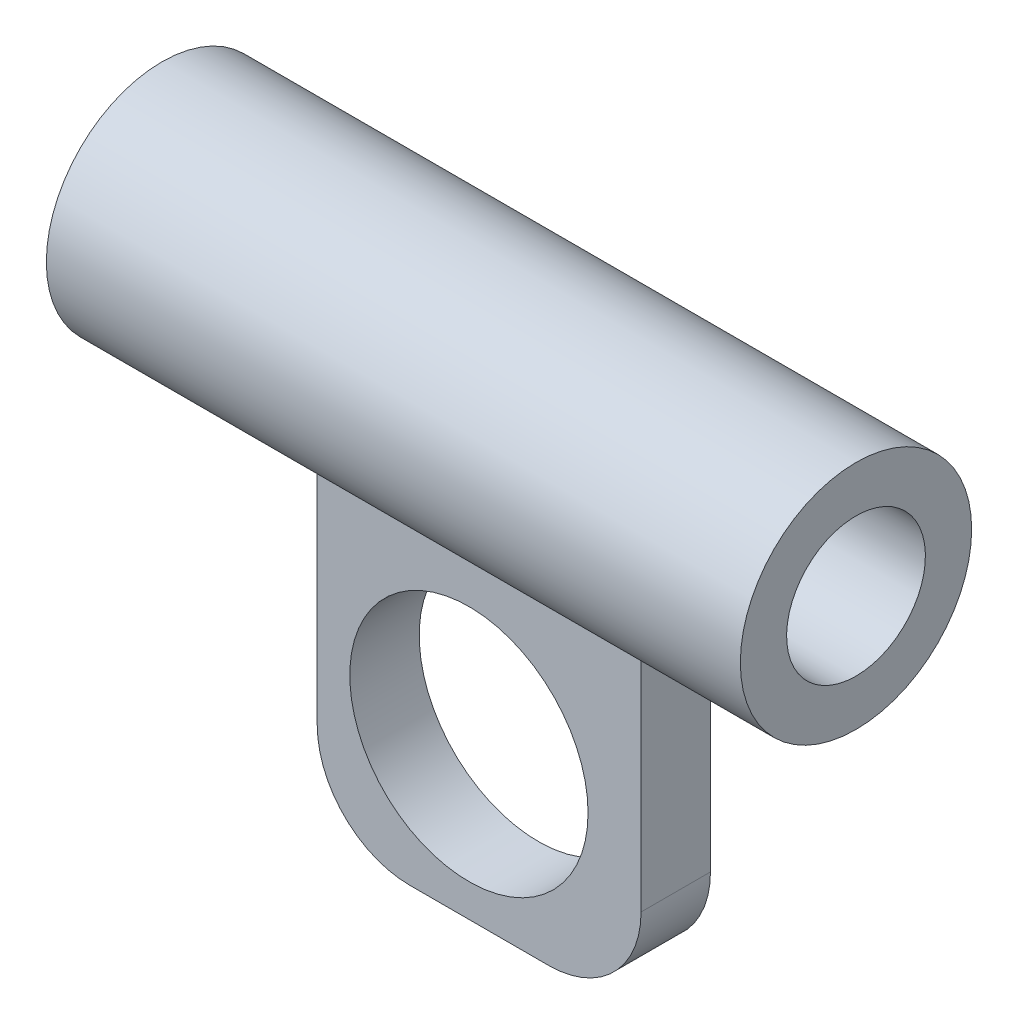
from build123d import *

# Parameters (mm, degrees)
SKETCH2_R                = 5.15
BOSS_EXTRUDE1_DEPTH      = 3
SKETCH3_R                = 5
SKETCH3_R_2              = 3
BOSS_EXTRUDE2_DEPTH      = 15
BOSS_EXTRUDE2_DEPTH_BACK = 15
SKETCH5_R                = 3
CUT_EXTRUDE1_DEPTH       = 31.0000001


with BuildPart() as part:
    # Sketch2 → Boss-Extrude1 (new body)
    with BuildSketch(Plane.XY):
        with BuildLine():
            Line((4, 0), (10, 0))
            ThreePointArc((10, 0), (12.828427125, 1.171572875), (14, 4))
            Line((14, 4), (14, 16))
            ThreePointArc((14, 16), (12.828427125, 18.828427125), (10, 20))
            Line((10, 20), (4, 20))
            ThreePointArc((4, 20), (1.171572875, 18.828427125), (0, 16))
            Line((0, 16), (0, 4))
            ThreePointArc((0, 4), (1.171572875, 1.171572875), (4, 0))
        make_face()
        with Locations((6.558010351, 6.566011985)):
            Circle(SKETCH2_R, mode=Mode.SUBTRACT)
    extrude(amount=BOSS_EXTRUDE1_DEPTH)

    # Sketch3 → Boss-Extrude2 (add, two sides)
    with BuildSketch(Plane.ZY.offset(-7)) as boss_extrude2_sk:
        with Locations((1.709593121, 19.184703003)):
            Circle(SKETCH3_R)
        with Locations((1.709593121, 19.184703003)):
            Circle(SKETCH3_R_2, mode=Mode.SUBTRACT)
    extrude(amount=BOSS_EXTRUDE2_DEPTH)
    extrude(boss_extrude2_sk.sketch, amount=-BOSS_EXTRUDE2_DEPTH_BACK)

    # Sketch5 → Cut-Extrude1 (cut, through all)
    with BuildSketch(Plane(origin=(22, 0, 0), x_dir=(0, 0, -1), z_dir=(1, 0, 0))):
        with Locations((-1.709593121, 19.184703003)):
            Circle(SKETCH5_R)
    extrude(amount=-CUT_EXTRUDE1_DEPTH, mode=Mode.SUBTRACT)


solid = part.part
